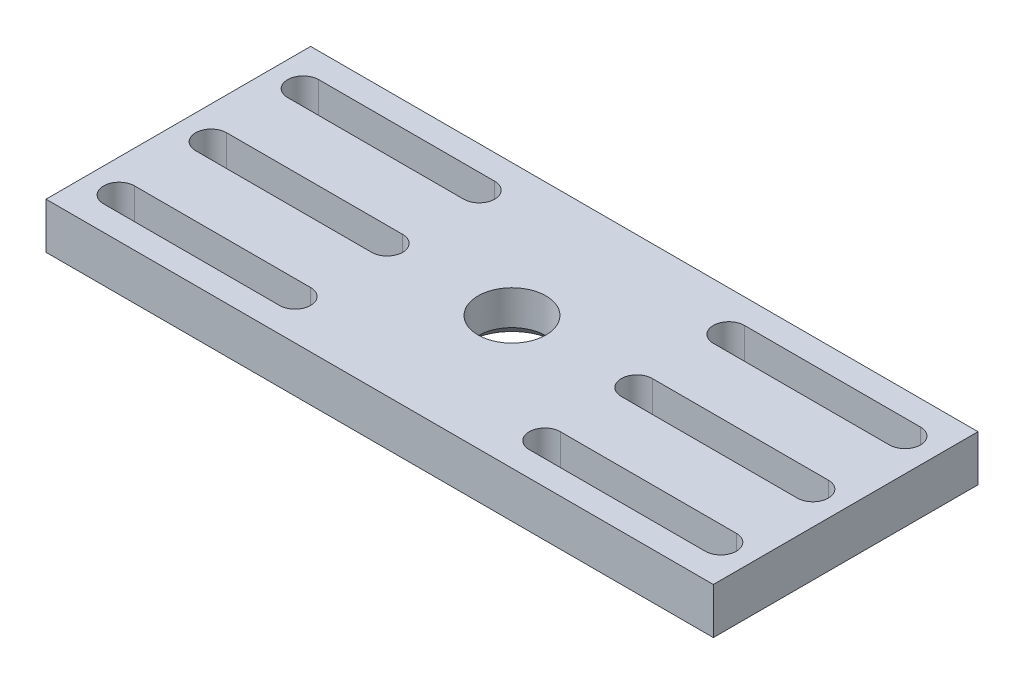
from build123d import *

# Parameters (mm, degrees)
SKETCH1_W           = 290
SKETCH1_H           = 115
BOSS_EXTRUDE1_DEPTH = 20
SKETCH2_R           = 14.75
CUT_EXTRUDE1_DEPTH  = 20
CHAMFER1_SIZE       = 5


with BuildPart() as part:
    # Sketch1 → Boss-Extrude1 (new body)
    with BuildSketch(Plane(origin=(0, 0, 0), x_dir=(1, 0, 0), z_dir=(0, 1, 0))):
        Rectangle(SKETCH1_W, SKETCH1_H)
    extrude(amount=BOSS_EXTRUDE1_DEPTH)

    # Sketch2 → Cut-Extrude1 (cut)
    with BuildSketch(Plane(origin=(0, 20, 0), x_dir=(1, 0, 0), z_dir=(0, 1, 0))):
        Circle(SKETCH2_R)
        with BuildLine():
            Line((-130.75, 6.75), (-54.25, 6.75))
            ThreePointArc((-54.25, 6.75), (-47.5, 0), (-54.25, -6.75))
            Line((-54.25, -6.75), (-130.75, -6.75))
            ThreePointArc((-130.75, -6.75), (-137.5, 0), (-130.75, 6.75))
        make_face()
        with BuildLine():
            Line((-130.75, 46.75), (-54.25, 46.75))
            ThreePointArc((-54.25, 46.75), (-47.5, 40), (-54.25, 33.25))
            Line((-54.25, 33.25), (-130.75, 33.25))
            ThreePointArc((-130.75, 33.25), (-137.5, 40), (-130.75, 46.75))
        make_face()
        with BuildLine():
            Line((-130.75, -33.25), (-54.25, -33.25))
            ThreePointArc((-54.25, -33.25), (-47.5, -40), (-54.25, -46.75))
            Line((-54.25, -46.75), (-130.75, -46.75))
            ThreePointArc((-130.75, -46.75), (-137.5, -40), (-130.75, -33.25))
        make_face()
        with BuildLine():
            Line((54.25, 6.75), (130.75, 6.75))
            ThreePointArc((130.75, 6.75), (137.5, 0), (130.75, -6.75))
            Line((130.75, -6.75), (54.25, -6.75))
            ThreePointArc((54.25, -6.75), (47.5, 0), (54.25, 6.75))
        make_face()
        with BuildLine():
            Line((54.25, -33.25), (130.75, -33.25))
            ThreePointArc((130.75, -33.25), (137.5, -40), (130.75, -46.75))
            Line((130.75, -46.75), (54.25, -46.75))
            ThreePointArc((54.25, -46.75), (47.5, -40), (54.25, -33.25))
        make_face()
        with BuildLine():
            Line((54.25, 46.75), (130.75, 46.75))
            ThreePointArc((130.75, 46.75), (137.5, 40), (130.75, 33.25))
            Line((130.75, 33.25), (54.25, 33.25))
            ThreePointArc((54.25, 33.25), (47.5, 40), (54.25, 46.75))
        make_face()
    extrude(amount=-CUT_EXTRUDE1_DEPTH, mode=Mode.SUBTRACT)

    # Chamfer1
    chamfer1_edges = [part.edges().sort_by_distance(p)[0] for p in [
        (-14.75, 0, 0),
    ]]
    chamfer(chamfer1_edges, length=CHAMFER1_SIZE)


solid = part.part
